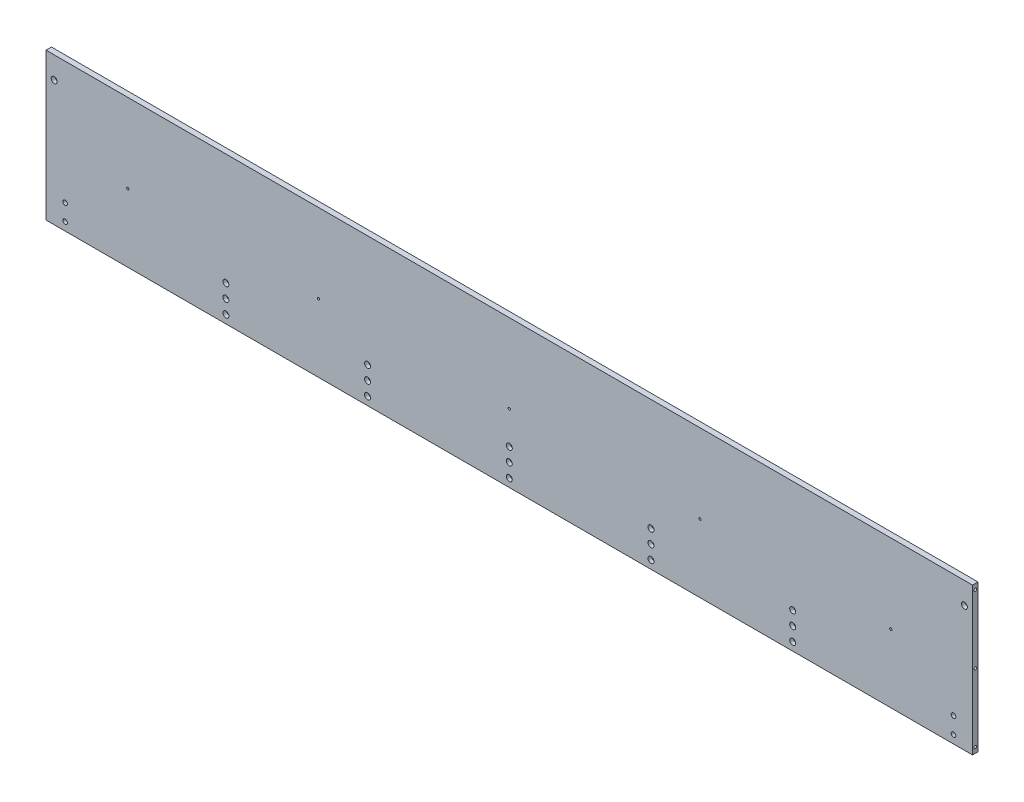
from build123d import *

# Parameters (mm, degrees)
SKETCH_1_W                          = 1700
SKETCH_1_H                          = 270
EXTRUDE_1_DEPTH                     = 5
HOLE_WIZARD_M6_1_AT_2_COUNT         = 2
HOLE_WIZARD_M6_1_AT_2_PITCH         = 250
HOLE_WIZARD_M6_1_AT_3_COUNT         = 2
HOLE_WIZARD_M6_1_AT_3_PITCH         = 125
HOLE_WIZARD_3_D                     = 6.6
HOLE_WIZARD_3_CBORE_D               = 11
HOLE_WIZARD_3_CBORE_DEPTH           = 6.8
PATTERN_LINEAR_1_COUNT              = 3
PATTERN_LINEAR_1_PITCH              = 25
PATTERN_LINEAR_1_COPY_1_D           = 6.6
PATTERN_LINEAR_1_COPY_1_CBORE_D     = 11
PATTERN_LINEAR_1_COPY_1_CBORE_DEPTH = 6.8
PATTERN_LINEAR_1_COPY_2_D           = 6.6
PATTERN_LINEAR_1_COPY_2_CBORE_D     = 11
PATTERN_LINEAR_1_COPY_2_CBORE_DEPTH = 6.8
HOLE_WIZARD_M5_1_D                  = 4.2
HOLE_WIZARD_3_2_D                   = 6.6
HOLE_WIZARD_3_2_CBORE_D             = 11
HOLE_WIZARD_3_2_CBORE_DEPTH         = 6.8
HOLE_WIZARD_3_3_D                   = 6.6
HOLE_WIZARD_3_3_CBORE_D             = 11
HOLE_WIZARD_3_3_CBORE_DEPTH         = 6.8
HOLE_WIZARD_M10_1_D                 = 8.5


with BuildPart() as part:
    # 草图1 → 凸台-拉伸1 (new body, symmetric)
    with BuildSketch(Plane.XY):
        Rectangle(SKETCH_1_W, SKETCH_1_H)
    extrude(amount=EXTRUDE_1_DEPTH, both=True)

    # 草图5 → M6 螺纹孔1 (revolve, cut)
    with BuildSketch(Plane(origin=(-850, 125, 0), x_dir=(0, 0, 1), z_dir=(0, 1, 0))):
        Polygon((0, 0), (0, 16.502151548), (2.5, 15), (2.5, 0), align=None)
    hole_wizard_m6_1 = revolve(axis=Axis((-856.35, 125, 0), (1, 0, 0)), mode=Mode.SUBTRACT)

    # M6 螺纹孔1 at 2: M6 螺纹孔1 ×2
    with Locations(*[(0, -i * HOLE_WIZARD_M6_1_AT_2_PITCH, 0) for i in range(1, HOLE_WIZARD_M6_1_AT_2_COUNT)]):
        add(hole_wizard_m6_1, mode=Mode.SUBTRACT)

    # M6 螺纹孔1 at 3: M6 螺纹孔1 ×2
    with Locations(*[(0, -i * HOLE_WIZARD_M6_1_AT_3_PITCH, 0) for i in range(1, HOLE_WIZARD_M6_1_AT_3_COUNT)]):
        add(hole_wizard_m6_1, mode=Mode.SUBTRACT)

    # 镜向1: M6 螺纹孔1 across plane
    add(hole_wizard_m6_1.mirror(Plane(origin=(0, 0, 0), x_dir=(0, 0, 1), z_dir=(1, 0, 0))), mode=Mode.SUBTRACT)

    # 镜向1 copy 1 sketch → 镜向1 copy 1 (revolve, cut)
    with BuildSketch(Plane(origin=(850, -125, 0), x_dir=(0, 0, 1), z_dir=(0, 1, 0))):
        Polygon((0, 0), (0, -16.502151548), (2.5, -15), (2.5, 0), align=None)
    revolve(axis=Axis((856.35, -125, 0), (1, 0, 0)), mode=Mode.SUBTRACT)

    # 镜向1 copy 2 sketch → 镜向1 copy 2 (revolve, cut)
    with BuildSketch(Plane(origin=(850, 0, 0), x_dir=(0, 0, 1), z_dir=(0, 1, 0))):
        Polygon((0, 0), (0, -16.502151548), (2.5, -15), (2.5, 0), align=None)
    revolve(axis=Axis((856.35, 0, 0), (1, 0, 0)), mode=Mode.SUBTRACT)

    # Hole Wizard 3 (through all)
    with Locations(Plane(origin=(-520, -70, 5), x_dir=(1, 0, 0), z_dir=(0, 0, 1))):
        with Locations((0, 0), (260, 0), (520, 0)):
            hole_wizard_3 = CounterBoreHole(HOLE_WIZARD_3_D / 2, HOLE_WIZARD_3_CBORE_D / 2, HOLE_WIZARD_3_CBORE_DEPTH)

    # 镜向4: Hole Wizard 3 across plane
    add(hole_wizard_3.mirror(Plane(origin=(0, 0, 0), x_dir=(0, 0, 1), z_dir=(1, 0, 0))), mode=Mode.SUBTRACT)

    # 阵列(线性)1: Hole Wizard 3 ×3
    with Locations(*[(0, -i * PATTERN_LINEAR_1_PITCH, 0) for i in range(1, PATTERN_LINEAR_1_COUNT)]):
        add(hole_wizard_3, mode=Mode.SUBTRACT)

    # 阵列(线性)1 copy 1 (through all)
    with Locations(Plane(origin=(520, -95, 5), x_dir=(-1, 0, 0), z_dir=(0, 0, 1))):
        with Locations((0, 0), (260, 0), (520, 0)):
            CounterBoreHole(PATTERN_LINEAR_1_COPY_1_D / 2, PATTERN_LINEAR_1_COPY_1_CBORE_D / 2, PATTERN_LINEAR_1_COPY_1_CBORE_DEPTH)

    # 阵列(线性)1 copy 2 (through all)
    with Locations(Plane(origin=(520, -120, 5), x_dir=(-1, 0, 0), z_dir=(0, 0, 1))):
        with Locations((0, 0), (260, 0), (520, 0)):
            CounterBoreHole(PATTERN_LINEAR_1_COPY_2_D / 2, PATTERN_LINEAR_1_COPY_2_CBORE_D / 2, PATTERN_LINEAR_1_COPY_2_CBORE_DEPTH)

    # M5 螺纹孔1 (through all)
    with Locations(Plane(origin=(-700, -10, 5), x_dir=(1, 0, 0), z_dir=(0, 0, 1))):
        with Locations((0, 0), (350, 0), (1400, 0), (1050, 0), (700, 0)):
            Hole(HOLE_WIZARD_M5_1_D / 2)

    # Hole Wizard 3 2 (through all)
    with Locations(Plane(origin=(835, 95, 5), x_dir=(1, 0, 0), z_dir=(0, 0, 1))):
        with Locations((0, 0)):
            CounterBoreHole(HOLE_WIZARD_3_2_D / 2, HOLE_WIZARD_3_2_CBORE_D / 2, HOLE_WIZARD_3_2_CBORE_DEPTH)

    # Hole Wizard 3 3 (through all)
    with Locations(Plane(origin=(-835, 95, 5), x_dir=(1, 0, 0), z_dir=(0, 0, 1))):
        with Locations((0, 0)):
            CounterBoreHole(HOLE_WIZARD_3_3_D / 2, HOLE_WIZARD_3_3_CBORE_D / 2, HOLE_WIZARD_3_3_CBORE_DEPTH)

    # M10 螺纹孔1 (through all)
    with Locations(Plane(origin=(-815, -90, 5), x_dir=(1, 0, 0), z_dir=(0, 0, 1))):
        with Locations((0, 0), (0, -30)):
            hole_wizard_m10_1 = Hole(HOLE_WIZARD_M10_1_D / 2)

    # 镜向5: M10 螺纹孔1 across plane
    add(hole_wizard_m10_1.mirror(Plane(origin=(0, 0, 0), x_dir=(0, 0, 1), z_dir=(1, 0, 0))), mode=Mode.SUBTRACT)


solid = part.part
